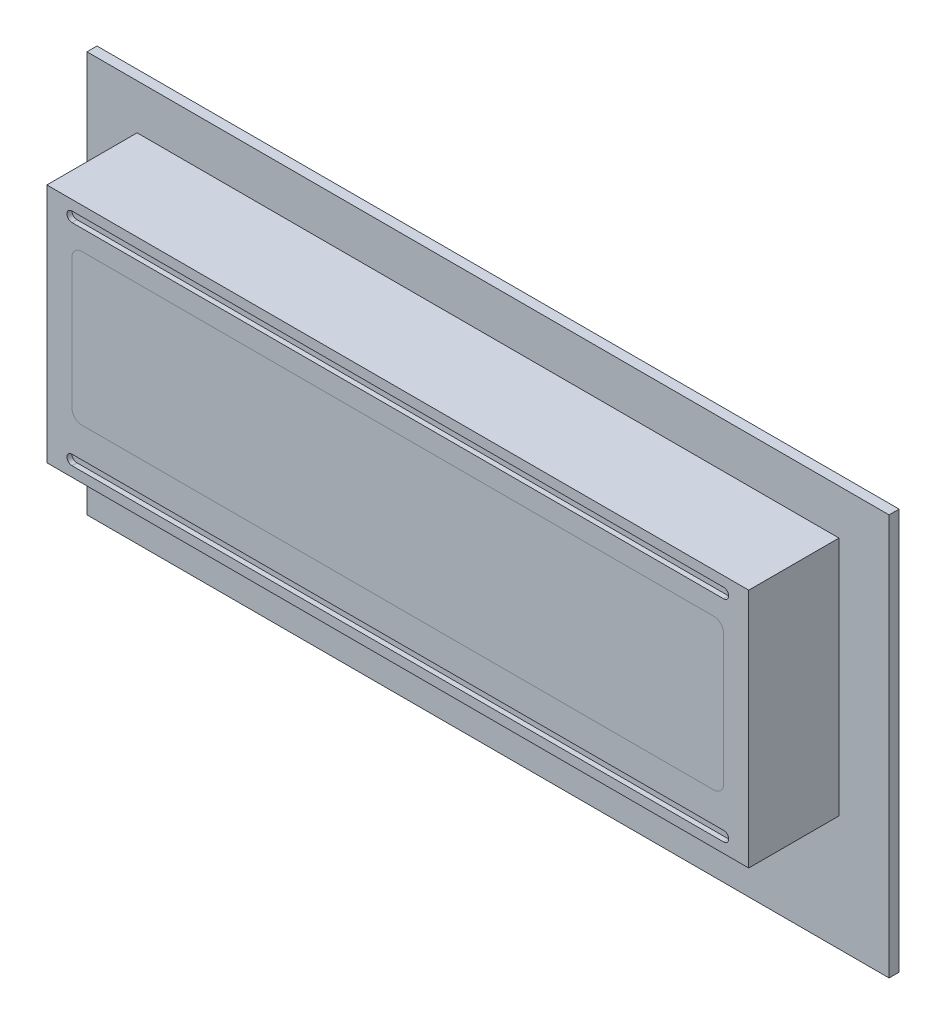
from build123d import *

# Parameters (mm, degrees)
ESQUISSE1_W             = 80
ESQUISSE1_H             = 40
BOSS_EXTRU_1_DEPTH      = 1
ESQUISSE2_W             = 70
ESQUISSE2_H             = 24
BOSS_EXTRU_2_DEPTH      = 9
ENL_V_MAT_EXTRU_1_DEPTH = 0.5
BOSS_EXTRU_4_DEPTH      = 1


with BuildPart() as part:
    # Esquisse1 → Boss.-Extru.1 (new body)
    with BuildSketch(Plane.XY):
        Rectangle(ESQUISSE1_W, ESQUISSE1_H)
    extrude(amount=BOSS_EXTRU_1_DEPTH)

    # Esquisse2 → Boss.-Extru.2 (add)
    with BuildSketch(Plane.XY.offset(1)):
        with Locations((0, 3.5)):
            Rectangle(ESQUISSE2_W, ESQUISSE2_H)
        with BuildLine():
            Line((-31.5, 11.5), (31.5, 11.5))
            ThreePointArc((31.5, 11.5), (32.207106781, 11.207106781), (32.5, 10.5))
            Line((32.5, 10.5), (32.5, -2.5))
            ThreePointArc((32.5, -2.5), (32.207106781, -3.207106781), (31.5, -3.5))
            Line((31.5, -3.5), (-31.5, -3.5))
            ThreePointArc((-31.5, -3.5), (-32.207106781, -3.207106781), (-32.5, -2.5))
            Line((-32.5, -2.5), (-32.5, 10.5))
            ThreePointArc((-32.5, 10.5), (-32.207106781, 11.207106781), (-31.5, 11.5))
        make_face(mode=Mode.SUBTRACT)
    extrude(amount=BOSS_EXTRU_2_DEPTH)

    # Esquisse3 → Enlèv. mat.-Extru.1 (cut)
    with BuildSketch(Plane.XY.offset(10)):
        with BuildLine():
            Line((-32.5, 14.5), (32.5, 14.5))
            ThreePointArc((32.5, 14.5), (33, 14), (32.5, 13.5))
            Line((32.5, 13.5), (-32.5, 13.5))
            ThreePointArc((-32.5, 13.5), (-33, 14), (-32.5, 14.5))
        make_face()
        with BuildLine():
            Line((-32.5, -6.5), (32.5, -6.5))
            ThreePointArc((32.5, -6.5), (33, -7), (32.5, -7.5))
            Line((32.5, -7.5), (-32.5, -7.5))
            ThreePointArc((-32.5, -7.5), (-33, -7), (-32.5, -6.5))
        make_face()
    extrude(amount=-ENL_V_MAT_EXTRU_1_DEPTH, mode=Mode.SUBTRACT)


with BuildPart() as body_2:
    # Esquisse4 → Boss.-Extru.4 (new body)
    with BuildSketch(Plane.XY.offset(10)):
        with BuildLine():
            Line((32.5, -2.5), (32.5, 10.5))
            ThreePointArc((32.5, 10.5), (32.207106781, 11.207106781), (31.5, 11.5))
            Line((31.5, 11.5), (-31.5, 11.5))
            ThreePointArc((-31.5, 11.5), (-32.207106781, 11.207106781), (-32.5, 10.5))
            Line((-32.5, 10.5), (-32.5, -2.5))
            ThreePointArc((-32.5, -2.5), (-32.207106781, -3.207106781), (-31.5, -3.5))
            Line((-31.5, -3.5), (31.5, -3.5))
            ThreePointArc((31.5, -3.5), (32.207106781, -3.207106781), (32.5, -2.5))
        make_face()
    extrude(amount=-BOSS_EXTRU_4_DEPTH)


solid = Compound([part.part, body_2.part])
